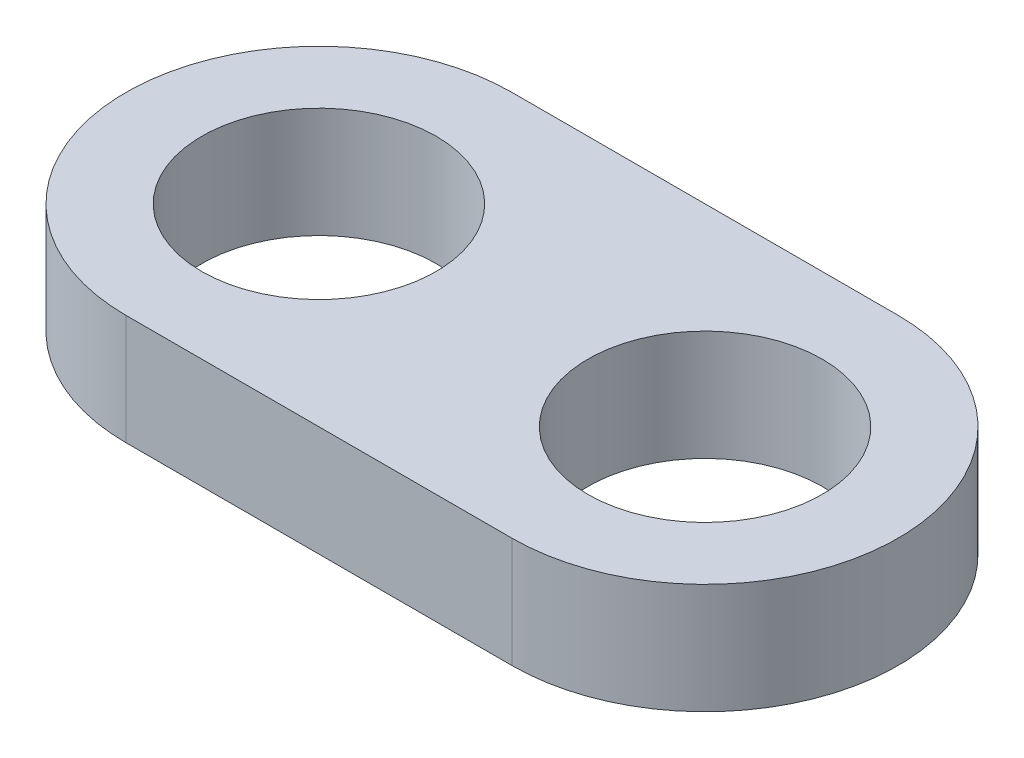
from build123d import *

# Parameters (mm, degrees)
SKETCH1_R           = 2.125
BOSS_EXTRUDE1_DEPTH = 1


with BuildPart() as part:
    # Sketch1 → Boss-Extrude1 (new body, symmetric)
    with BuildSketch(Plane(origin=(0, 0, 0), x_dir=(1, 0, 0), z_dir=(0, 1, 0))):
        with BuildLine():
            Line((-3.5, 3.5), (3.5, 3.5))
            ThreePointArc((3.5, 3.5), (7, 0), (3.5, -3.5))
            Line((3.5, -3.5), (-3.5, -3.5))
            ThreePointArc((-3.5, -3.5), (-7, 0), (-3.5, 3.5))
        make_face()
        with Locations((-3.5, 0)):
            Circle(SKETCH1_R, mode=Mode.SUBTRACT)
        with Locations((3.5, 0)):
            Circle(SKETCH1_R, mode=Mode.SUBTRACT)
    extrude(amount=BOSS_EXTRUDE1_DEPTH, both=True)


solid = part.part
